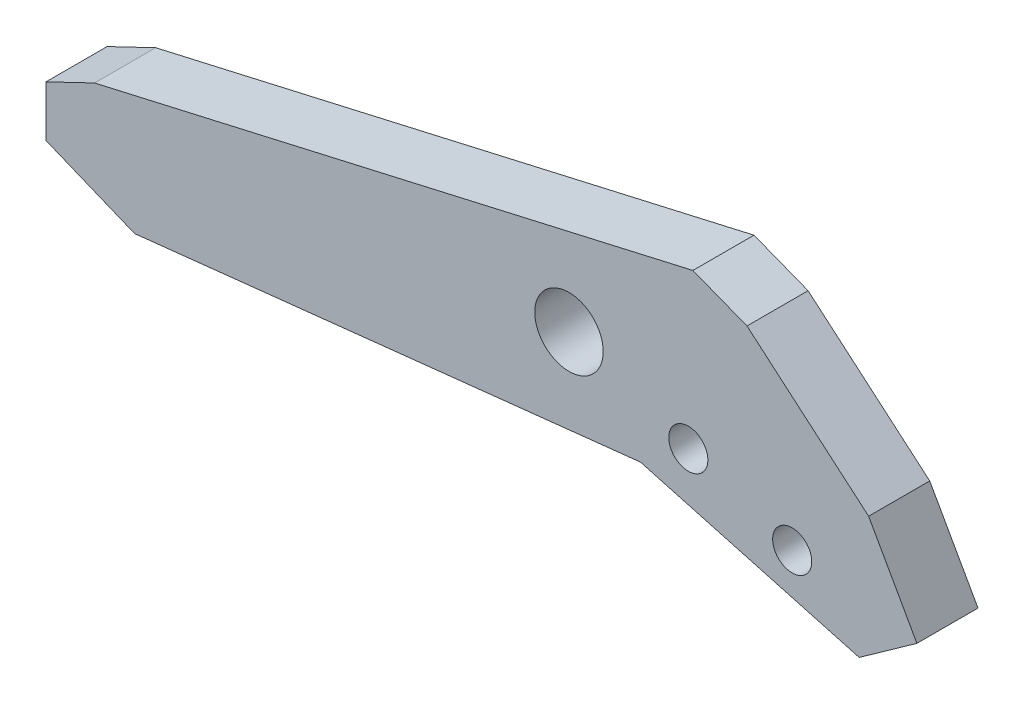
from build123d import *

# Parameters (mm, degrees)
BOSS_EXTRUDE1_DEPTH = 3.175
SKETCH2_R           = 1.016
SKETCH2_R_2         = 1.778
CUT_EXTRUDE1_DEPTH  = 4.175


with BuildPart() as part:
    # Sketch1 → Boss-Extrude1 (new body)
    with BuildSketch(Plane.XY):
        Polygon((14.202193653, 7.22569581), (20.522953668, 1.825587343), (23.031425106, -2.643692959), (20.033036873, -4.776381895), (8.666728722, -1.668226656), (-17.619055751, -4.527501407), (-22.225, -2.643692959), (-22.225, 0), (-19.700320896, 1.210279341), (0, 5.715), (11.391452648, 8.319795747), align=None)
    extrude(amount=BOSS_EXTRUDE1_DEPTH)

    # Sketch2 → Cut-Extrude1 (cut, through all)
    with BuildSketch(Plane.XY.offset(3.175)):
        with Locations((11.153208162, 0.17748796)):
            Circle(SKETCH2_R)
        with Locations((16.551157276, -1.699576334)):
            Circle(SKETCH2_R)
        with Locations((4.951564402, 2.334026271)):
            Circle(SKETCH2_R_2)
    extrude(amount=-CUT_EXTRUDE1_DEPTH, mode=Mode.SUBTRACT)


solid = part.part
